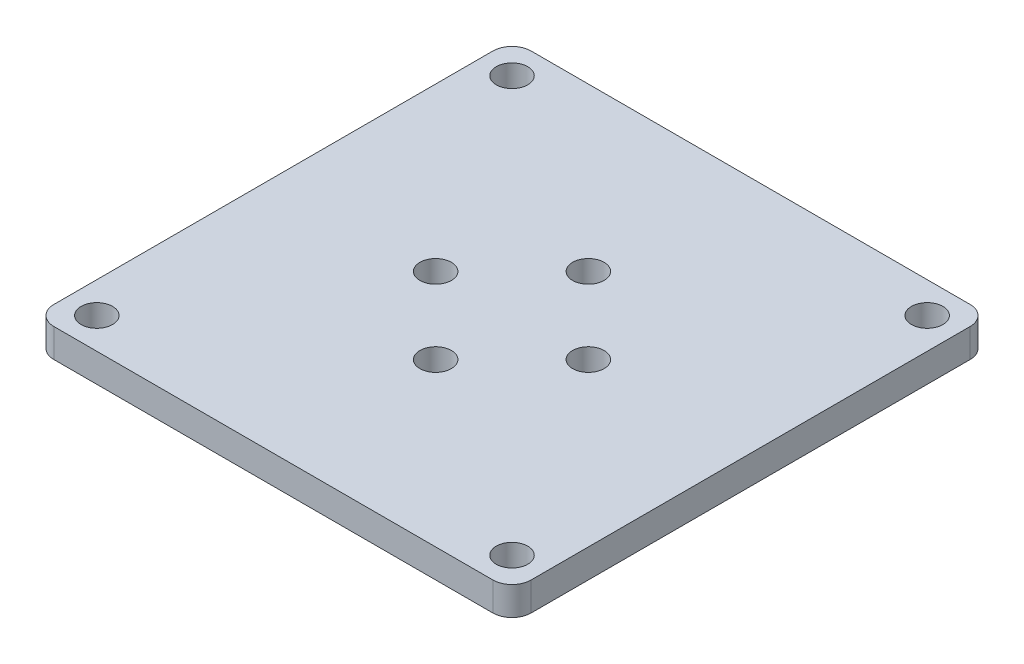
from build123d import *

# Parameters (mm, degrees)
SKETCH_1_W      = 50
SKETCH_1_H      = 50
SKETCH_1_R      = 1.65
EXTRUDE_2_DEPTH = 3
FILLET_1_R      = 2
FILLET_2_R      = 2
FILLET_3_R      = 2
FILLET_4_R      = 2


with BuildPart() as part:
    # 草图1 → 凸台-拉伸2 (new body)
    with BuildSketch(Plane(origin=(0, 0, 0), x_dir=(1, 0, 0), z_dir=(0, 1, 0))):
        Rectangle(SKETCH_1_W, SKETCH_1_H)
        with Locations((21.75, 21.75)):
            Circle(SKETCH_1_R, mode=Mode.SUBTRACT)
        with Locations((-21.75, 21.75)):
            Circle(SKETCH_1_R, mode=Mode.SUBTRACT)
        with Locations((21.75, -21.75)):
            Circle(SKETCH_1_R, mode=Mode.SUBTRACT)
        with Locations((-21.75, -21.75)):
            Circle(SKETCH_1_R, mode=Mode.SUBTRACT)
        with Locations((8, 0)):
            Circle(SKETCH_1_R, mode=Mode.SUBTRACT)
        with Locations((0, 8)):
            Circle(SKETCH_1_R, mode=Mode.SUBTRACT)
        with Locations((-8, 0)):
            Circle(SKETCH_1_R, mode=Mode.SUBTRACT)
        with Locations((0, -8)):
            Circle(SKETCH_1_R, mode=Mode.SUBTRACT)
    extrude(amount=EXTRUDE_2_DEPTH)

    # 圆角1
    fillet_1_edges = [part.edges().sort_by_distance(p)[0] for p in [
        (25, 1.5, 25),
    ]]
    fillet(fillet_1_edges, radius=FILLET_1_R)

    # 圆角2
    fillet_2_edges = [part.edges().sort_by_distance(p)[0] for p in [
        (25, 1.5, -25),
    ]]
    fillet(fillet_2_edges, radius=FILLET_2_R)

    # 圆角3
    fillet_3_edges = [part.edges().sort_by_distance(p)[0] for p in [
        (-25, 1.5, -25),
    ]]
    fillet(fillet_3_edges, radius=FILLET_3_R)

    # 圆角4
    fillet_4_edges = [part.edges().sort_by_distance(p)[0] for p in [
        (-25, 1.5, 25),
    ]]
    fillet(fillet_4_edges, radius=FILLET_4_R)


solid = part.part
